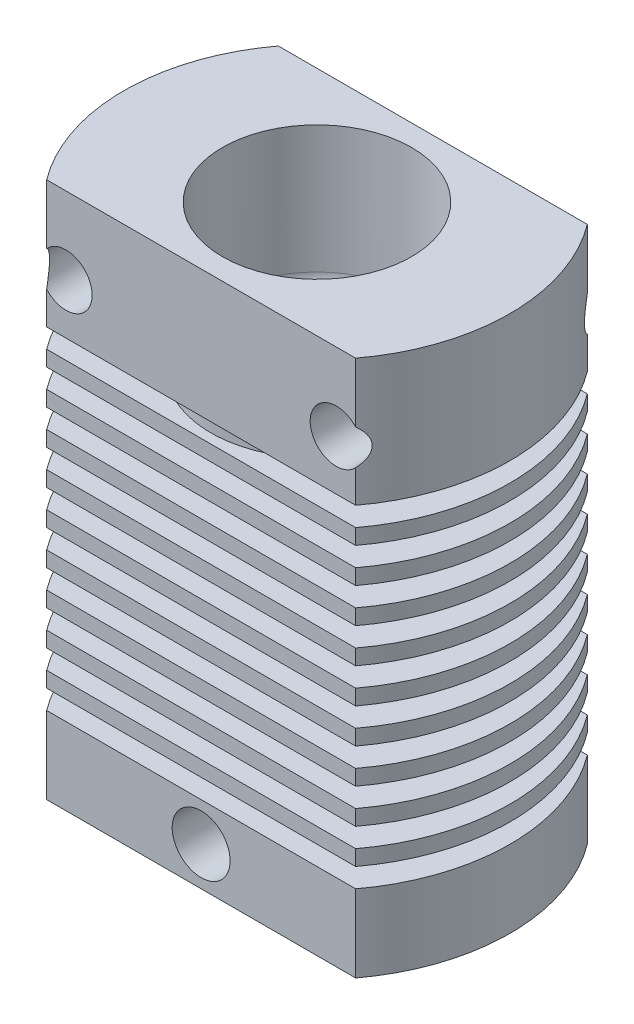
from build123d import *

# Parameters (mm, degrees)
SKETCH1_W          = 20
SKETCH1_H          = 27.8
BODY_DEPTH         = 6
BODY_DEPTH_BACK    = 6
SKETCH2_W          = 20
SKETCH2_H          = 1
CUTTHROUGH_DEPTH   = 13
RIBS_COUNT         = 10
RIBS_PITCH         = 1.8
SKETCH3_R          = 1.353942753
TOP_HOLES_DEPTH    = 13
SKETCH4_R          = 1.5
LOWERHOLE_DEPTH    = 6
SKETCH5_R          = 20
SKETCH5_R_2        = 10
CYLINDER_DEPTH     = 28.8
SKETCH6_R          = 4.3
CENTRE_ROD_DEPTH   = 23.8
SKETCH7_R          = 5.5
SKETCH7_R_2        = 4.9
UPPER_ROD_DEPTH    = 7.6
SKETCH7_2_R        = 4.9
UP_HOLE_DEPTH      = 7.6
SKETCH9_R          = 1.5
BOTTOM_HOLE_DEPTH  = 5
SKETCH10_R         = 3.5
CUT_EXTRUDE7_DEPTH = 21.2
FILLET1_R          = 1
FILLET2_R          = 1


with BuildPart() as part:
    # Sketch1 → body (new body, two sides)
    with BuildSketch(Plane.XY) as body_sk:
        Rectangle(SKETCH1_W, SKETCH1_H)
    extrude(amount=BODY_DEPTH)
    extrude(body_sk.sketch, amount=-BODY_DEPTH_BACK)

    # Sketch2 → cutThrough (cut, through all)
    with BuildSketch(Plane.XY.offset(6)):
        with Locations((0, -9.4)):
            Rectangle(SKETCH2_W, SKETCH2_H)
    cutthrough = extrude(amount=-CUTTHROUGH_DEPTH, mode=Mode.SUBTRACT)

    # ribs: cutThrough ×10
    with Locations(*[(0, i * RIBS_PITCH, 0) for i in range(1, RIBS_COUNT)]):
        add(cutthrough, mode=Mode.SUBTRACT)

    # Sketch3 → top holes (cut, through all)
    with BuildSketch(Plane.XY.offset(6)):
        with Locations((-7, 9.9)):
            Circle(SKETCH3_R)
    top_holes = extrude(amount=-TOP_HOLES_DEPTH, mode=Mode.SUBTRACT)

    # top hole R: top holes across plane
    add(top_holes.mirror(Plane(origin=(0, 0, 0), x_dir=(0, 0, 1), z_dir=(1, 0, 0))), mode=Mode.SUBTRACT)

    # Sketch4 → lowerHole (cut)
    with BuildSketch(Plane.XY.offset(6)):
        with Locations((0, -11.9)):
            Circle(SKETCH4_R)
    extrude(amount=-LOWERHOLE_DEPTH, mode=Mode.SUBTRACT)

    # Sketch5 → cylinder (cut, through all)
    with BuildSketch(Plane(origin=(0, 13.9, 0), x_dir=(1, 0, 0), z_dir=(0, 1, 0))):
        Circle(SKETCH5_R)
        Circle(SKETCH5_R_2, mode=Mode.SUBTRACT)
    extrude(amount=-CYLINDER_DEPTH, mode=Mode.SUBTRACT)

    # Sketch6 → centre rod (add)
    with BuildSketch(Plane(origin=(0, 13.9, 0), x_dir=(1, 0, 0), z_dir=(0, 1, 0))):
        Circle(SKETCH6_R)
    extrude(amount=-CENTRE_ROD_DEPTH)

    # Sketch7 → upper rod (add)
    with BuildSketch(Plane(origin=(0, 13.9, 0), x_dir=(1, 0, 0), z_dir=(0, 1, 0))):
        Circle(SKETCH7_R)
        Circle(SKETCH7_R_2, mode=Mode.SUBTRACT)
    extrude(amount=-UPPER_ROD_DEPTH)

    # Sketch7_2 → up hole (cut)
    with BuildSketch(Plane(origin=(0, 13.9, 0), x_dir=(1, 0, 0), z_dir=(0, 1, 0))):
        Circle(SKETCH7_2_R)
    extrude(amount=-UP_HOLE_DEPTH, mode=Mode.SUBTRACT)

    # Sketch9 → bottom hole (cut)
    with BuildSketch(Plane.XZ.offset(13.9)):
        with Locations((-7, -1.5)):
            Circle(SKETCH9_R)
    bottom_hole = extrude(amount=-BOTTOM_HOLE_DEPTH, mode=Mode.SUBTRACT)

    # bottom hole R: bottom hole across plane
    add(bottom_hole.mirror(Plane(origin=(0, 0, 0), x_dir=(0, 0, 1), z_dir=(1, 0, 0))), mode=Mode.SUBTRACT)

    # Sketch10 → Cut-Extrude7 (cut, through all)
    with BuildSketch(Plane(origin=(0, 6.3, 0), x_dir=(1, 0, 0), z_dir=(0, 1, 0))):
        Circle(SKETCH10_R)
    extrude(amount=-CUT_EXTRUDE7_DEPTH, mode=Mode.SUBTRACT)

    # Fillet1
    fillet1_edges = [part.edges().sort_by_distance(p)[0] for p in [
        (-4.9, 6.3, 0),
    ]]
    fillet(fillet1_edges, radius=FILLET1_R)

    # Fillet2
    fillet2_edges = [part.edges().sort_by_distance(p)[0] for p in [
        (-3.5, 6.3, 0),
    ]]
    fillet(fillet2_edges, radius=FILLET2_R)


solid = part.part
